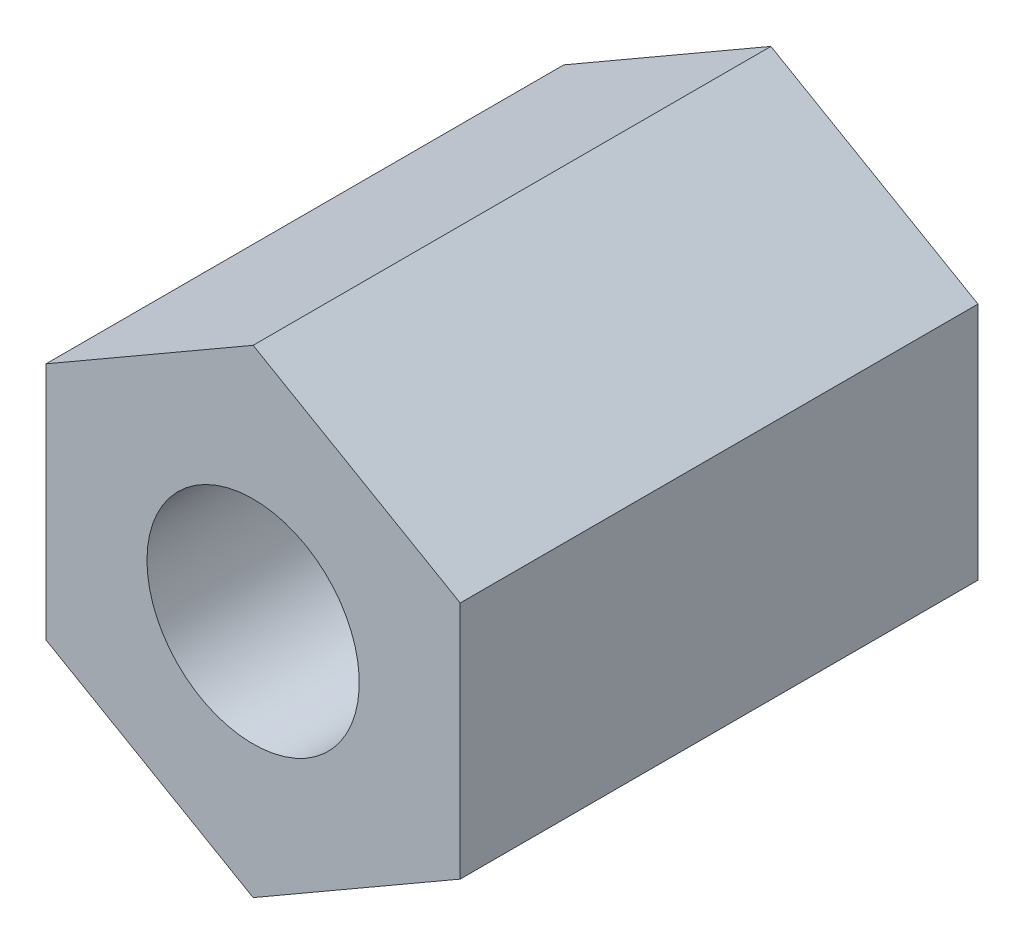
from build123d import *

# Parameters (mm, degrees)
BOSS_EXTRUDE1_DEPTH                       = 5
TROU_POUR_TARAUDAGE_POUR_TROU_TARAUD_M2_D = 2.05


with BuildPart() as part:
    # Sketch1 → Boss-Extrude1 (new body)
    with BuildSketch(Plane.XY):
        Polygon((0, -2.309401077), (2, -1.154700538), (2, 1.154700538), (0, 2.309401077), (-2, 1.154700538), (-2, -1.154700538), align=None)
    extrude(amount=BOSS_EXTRUDE1_DEPTH)

    # Trou pour taraudage pour trou taraudé M2.51 (through all)
    with Locations(Plane(origin=(0, 0, 0), x_dir=(-1, 0, 0), z_dir=(0, 0, -1))):
        with Locations((0, 0)):
            Hole(TROU_POUR_TARAUDAGE_POUR_TROU_TARAUD_M2_D / 2)


solid = part.part
